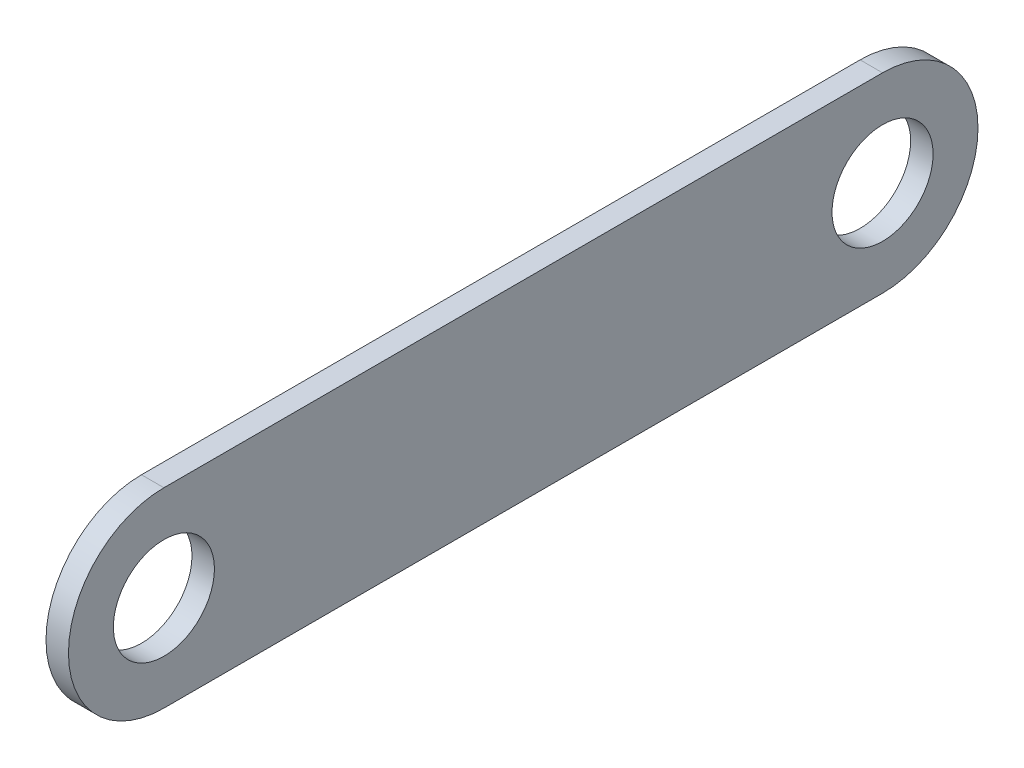
from build123d import *

# Parameters (mm, degrees)
SKETCH1_R           = 14.2875
BOSS_EXTRUDE1_DEPTH = 6.35


with BuildPart() as part:
    # Sketch1 → Boss-Extrude1 (new body)
    with BuildSketch(Plane(origin=(0, 0, 0), x_dir=(0, 0, -1), z_dir=(1, 0, 0))):
        with BuildLine():
            Line((0, 26.9875), (203.2, 26.9875))
            ThreePointArc((203.2, 26.9875), (230.1875, 0), (203.2, -26.9875))
            Line((203.2, -26.9875), (0, -26.9875))
            ThreePointArc((0, -26.9875), (-26.9875, 0), (0, 26.9875))
        make_face()
        Circle(SKETCH1_R, mode=Mode.SUBTRACT)
        with Locations((203.2, 0)):
            Circle(SKETCH1_R, mode=Mode.SUBTRACT)
    extrude(amount=BOSS_EXTRUDE1_DEPTH)


solid = part.part
